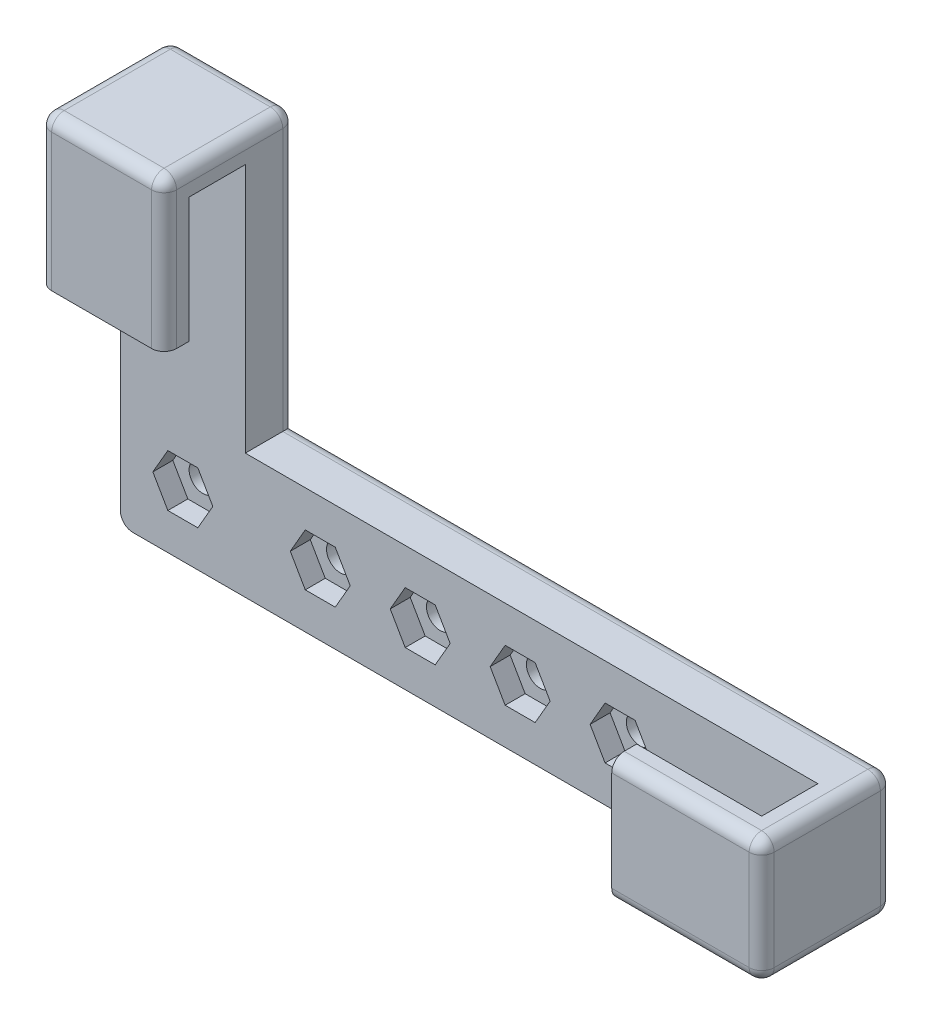
from build123d import *

# Parameters (mm, degrees)
BOSS_EXTRU_1_DEPTH      = 10
BOSS_EXTRU_2_DEPTH      = 10
CONG_1_R                = 1
ENL_V_MAT_EXTRU_1_REACH = 12.5
ESQUISSE5_R             = 1.1
ENL_V_MAT_EXTRU_2_DEPTH = 1.6


with BuildPart() as part:
    # Esquisse1 → Boss.-Extru.1 (new body)
    with BuildSketch(Plane(origin=(0, 0, 0), x_dir=(1, 0, 0), z_dir=(0, 1, 0))):
        Polygon((19.832159566, -6.5), (31.832159566, -6.5), (31.832159566, 4), (-26, 4), (-26, 0), (29.832159566, 0), (29.832159566, -4.5), (19.832159566, -4.5), align=None)
    extrude(amount=BOSS_EXTRU_1_DEPTH)

    # Esquisse4 → Boss.-Extru.2 (add)
    with BuildSketch(Plane.ZY.offset(26)):
        Polygon((-4, 10), (0, 10), (0, 30), (4.5, 30), (4.5, 20), (6.5, 20), (6.5, 32), (-4, 32), align=None)
    extrude(amount=-BOSS_EXTRU_2_DEPTH)

    # Congé1
    cong_1_edges = [part.edges().sort_by_distance(p)[0] for p in [
        (2.916079783, 0, -4),
        (31.832159566, 0, 1.25),
        (25.832159566, 0, 6.5),
        (31.832159566, 10, 1.25),
        (-26, 16, -4),
        (31.832159566, 5, -4),
        (31.832159566, 5, 6.5),
        (7.916079783, 10, -4),
        (-16, 21, -4),
        (-16, 32, 1.25),
        (-21, 32, -4),
        (-16, 26, 6.5),
        (-21, 32, 6.5),
        (-26, 26, 6.5),
        (-26, 32, 1.25),
        (25.832159566, 10, 6.5),
        (-26, 0, -2),
    ]]
    fillet(cong_1_edges, radius=CONG_1_R)

    # Esquisse5 → Enlèv. mat.-Extru.1 (cut, up to next)
    with BuildSketch(Plane(origin=(0, 0, -4), x_dir=(-1, 0, 0), z_dir=(0, 0, -1)), mode=Mode.PRIVATE) as enl_v_mat_extru_1_sk1:
        with Locations((10, 5)):
            Circle(ESQUISSE5_R)
    enl_v_mat_extru_1_tool1 = extrude(enl_v_mat_extru_1_sk1.sketch, amount=-ENL_V_MAT_EXTRU_1_REACH, mode=Mode.PRIVATE) & part.part
    add(enl_v_mat_extru_1_tool1.solids().sort_by_distance((-10, 5, -4))[0], mode=Mode.SUBTRACT)
    # Esquisse5 → Enlèv. mat.-Extru.1 (cut, up to next)
    with BuildSketch(Plane(origin=(0, 0, -4), x_dir=(-1, 0, 0), z_dir=(0, 0, -1)), mode=Mode.PRIVATE) as enl_v_mat_extru_1_sk2:
        with Locations((2, 5)):
            Circle(ESQUISSE5_R)
    enl_v_mat_extru_1_tool2 = extrude(enl_v_mat_extru_1_sk2.sketch, amount=-ENL_V_MAT_EXTRU_1_REACH, mode=Mode.PRIVATE) & part.part
    add(enl_v_mat_extru_1_tool2.solids().sort_by_distance((-2, 5, -4))[0], mode=Mode.SUBTRACT)
    # Esquisse5 → Enlèv. mat.-Extru.1 (cut, up to next)
    with BuildSketch(Plane(origin=(0, 0, -4), x_dir=(-1, 0, 0), z_dir=(0, 0, -1)), mode=Mode.PRIVATE) as enl_v_mat_extru_1_sk3:
        with Locations((-6, 5)):
            Circle(ESQUISSE5_R)
    enl_v_mat_extru_1_tool3 = extrude(enl_v_mat_extru_1_sk3.sketch, amount=-ENL_V_MAT_EXTRU_1_REACH, mode=Mode.PRIVATE) & part.part
    add(enl_v_mat_extru_1_tool3.solids().sort_by_distance((6, 5, -4))[0], mode=Mode.SUBTRACT)
    # Esquisse5 → Enlèv. mat.-Extru.1 (cut, up to next)
    with BuildSketch(Plane(origin=(0, 0, -4), x_dir=(-1, 0, 0), z_dir=(0, 0, -1)), mode=Mode.PRIVATE) as enl_v_mat_extru_1_sk4:
        with Locations((-14, 5)):
            Circle(ESQUISSE5_R)
    enl_v_mat_extru_1_tool4 = extrude(enl_v_mat_extru_1_sk4.sketch, amount=-ENL_V_MAT_EXTRU_1_REACH, mode=Mode.PRIVATE) & part.part
    add(enl_v_mat_extru_1_tool4.solids().sort_by_distance((14, 5, -4))[0], mode=Mode.SUBTRACT)
    # Esquisse5 → Enlèv. mat.-Extru.1 (cut, up to next)
    with BuildSketch(Plane(origin=(0, 0, -4), x_dir=(-1, 0, 0), z_dir=(0, 0, -1)), mode=Mode.PRIVATE) as enl_v_mat_extru_1_sk5:
        with Locations((21, 5)):
            Circle(ESQUISSE5_R)
    enl_v_mat_extru_1_tool5 = extrude(enl_v_mat_extru_1_sk5.sketch, amount=-ENL_V_MAT_EXTRU_1_REACH, mode=Mode.PRIVATE) & part.part
    add(enl_v_mat_extru_1_tool5.solids().sort_by_distance((-21, 5, -4))[0], mode=Mode.SUBTRACT)

    # Esquisse6 → Enlèv. mat.-Extru.2 (cut)
    with BuildSketch(Plane.XY):
        Polygon((12.8, 7.078460969), (11.6, 5), (12.8, 2.921539031), (15.2, 2.921539031), (16.4, 5), (15.2, 7.078460969), align=None)
        Polygon((4.8, 7.078460969), (3.6, 5), (4.8, 2.921539031), (7.2, 2.921539031), (8.4, 5), (7.2, 7.078460969), align=None)
        Polygon((-3.2, 7.078460969), (-4.4, 5), (-3.2, 2.921539031), (-0.8, 2.921539031), (0.4, 5), (-0.8, 7.078460969), align=None)
        Polygon((-11.2, 7.078460969), (-12.4, 5), (-11.2, 2.921539031), (-8.8, 2.921539031), (-7.6, 5), (-8.8, 7.078460969), align=None)
        Polygon((-22.2, 7.078460969), (-23.4, 5), (-22.2, 2.921539031), (-19.8, 2.921539031), (-18.6, 5), (-19.8, 7.078460969), align=None)
    extrude(amount=-ENL_V_MAT_EXTRU_2_DEPTH, mode=Mode.SUBTRACT)


solid = part.part
